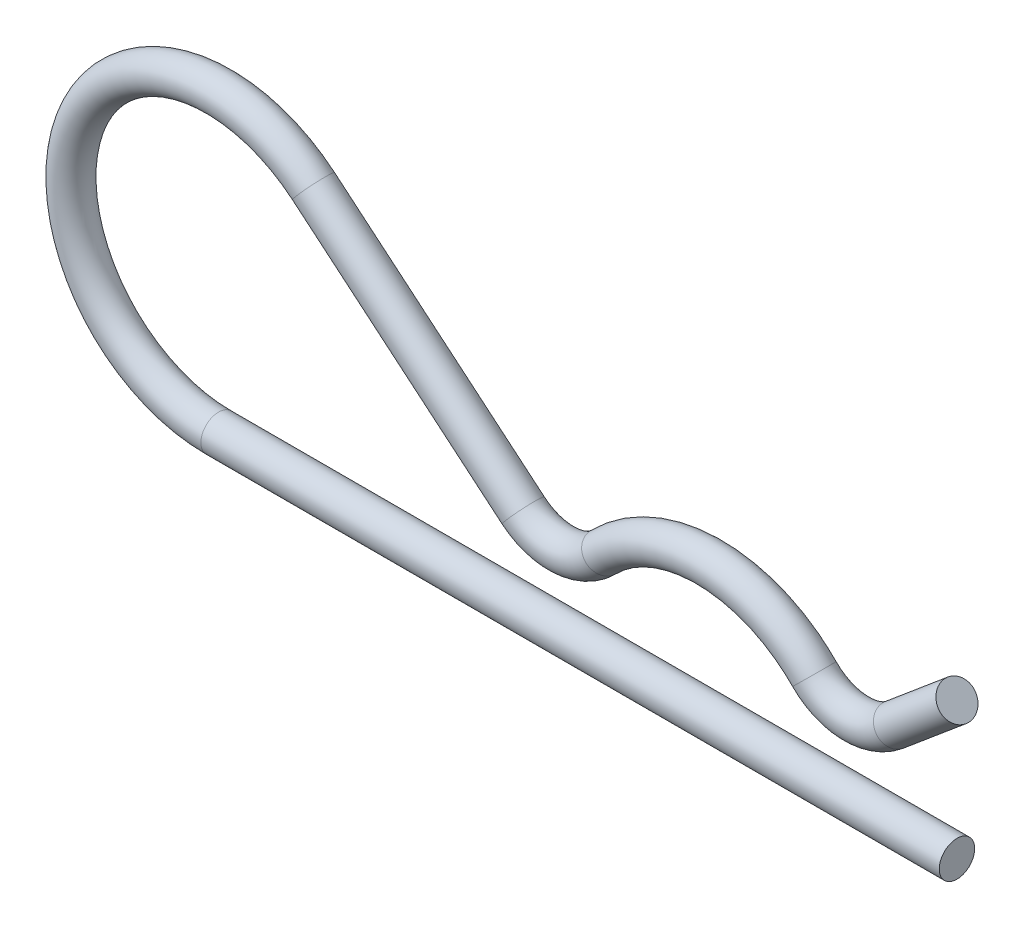
from build123d import *

# Parameters (mm, degrees)
SKETCH2_R = 1.524


with BuildPart() as part:
    # Sweep1: sweep along a path in Sketch1
    with BuildLine(Plane.XY) as sweep1_path:
        Line((0, 0), (-63.5, 0))
        ThreePointArc((-63.5, 0), (-75.434096284, 17.04365582), (-55.336597357, 22.428764428))
        Line((-55.336597357, 22.428764428), (-37.301361057, 7.2954043))
        ThreePointArc((-37.301361057, 7.2954043), (-33.788521012, 6.112941787), (-30.407428571, 7.631650673))
        ThreePointArc((-30.407428571, 7.631650673), (-21.336, 11.443502178), (-12.264571429, 7.631650673))
        ThreePointArc((-12.264571429, 7.631650673), (-8.883478988, 6.112941787), (-5.370638943, 7.2954043))
        Line((-5.370638943, 7.2954043), (0, 11.801905456))
    # Sketch2 → Sweep1 (sweep)
    with BuildSketch(Plane(origin=(0, 0, 0), x_dir=(0, 0, -1), z_dir=(1, 0, 0))):
        Circle(SKETCH2_R)
    sweep(path=sweep1_path.line)


solid = part.part
